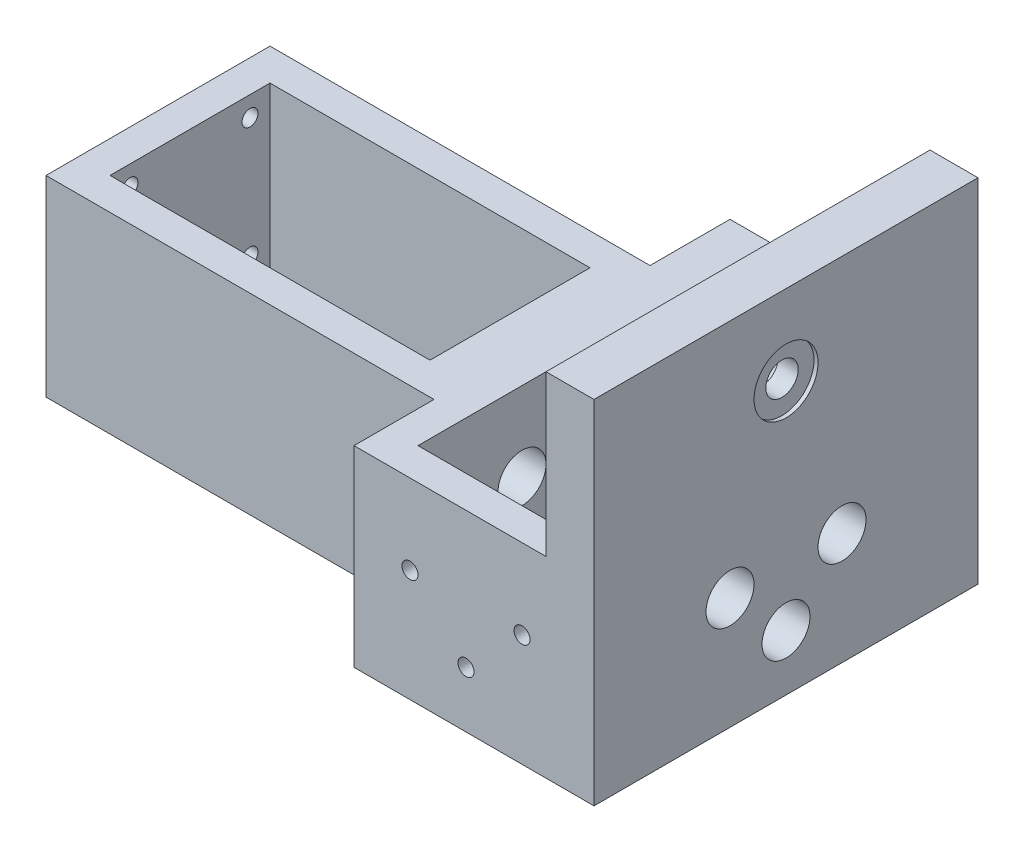
from build123d import *

# Parameters (mm, degrees)
BOSS_EXTRUDE1_DEPTH   = 5
SKETCH2_W             = 20
SKETCH2_H             = 40
SKETCH2_W_2           = 5
SKETCH2_H_2           = 20
BOSS_EXTRUDE2_DEPTH   = 20
SKETCH3_W             = 48.5
SKETCH3_H             = 25
BOSS_EXTRUDE3_DEPTH   = 4
SKETCH4_W             = 48.5
SKETCH4_H             = 25
BOSS_EXTRUDE4_DEPTH   = 4
SKETCH6_W             = 293.991294913
SKETCH6_H             = 166.612051016
CUT_EXTRUDE1_DEPTH    = 218
SKETCH7_W             = 4
SKETCH7_H             = 48
BOSS_EXTRUDE5_DEPTH   = 20
SKETCH8_W             = 48
SKETCH8_H             = 1
CUT_EXTRUDE2_DEPTH    = 87
SKETCH9_R             = 1
CUT_EXTRUDE3_DEPTH    = 10
SKETCH10_R            = 1
CUT_EXTRUDE4_DEPTH    = 60
SKETCH12_R            = 3
CUT_EXTRUDE5_DEPTH    = 29.5
SKETCH13_R            = 1
CUT_EXTRUDE6_DEPTH    = 29.5
SKETCH14_R            = 1
CUT_EXTRUDE7_DEPTH    = 29.5
SKETCH15_R            = 1.775
CUT_EXTRUDE8_DEPTH    = 29.5
SKETCH16_R            = 2.025
CUT_EXTRUDE9_DEPTH    = 29.5
SKETCH17_R            = 3.5
CUT_EXTRUDE10_DEPTH   = 3
SKETCH18_W            = 48
SKETCH18_H            = 44
SKETCH18_R            = 2.025
SKETCH18_R_2          = 3
BOSS_EXTRUDE6_DEPTH   = 2
CROQUIS2_R            = 4
CORTAR_EXTRUIR2_DEPTH = 0.5


with BuildPart() as part:
    # Sketch1 → Boss-Extrude1 (new body)
    with BuildSketch(Plane(origin=(0, 0, 0), x_dir=(1, 0, 0), z_dir=(0, 1, 0))):
        Polygon((-5, 20), (43.5, 20), (43.5, 35), (73.5, 35), (73.5, -15), (43.5, -15), (43.5, 0), (-5, 0), align=None)
    extrude(amount=BOSS_EXTRUDE1_DEPTH)

    # Sketch2 → Boss-Extrude2 (add)
    with BuildSketch(Plane(origin=(0, 5, 0), x_dir=(1, 0, 0), z_dir=(0, 1, 0))):
        Polygon((40, 20), (43.5, 20), (43.5, 35), (73.5, 35), (73.5, -15), (43.5, -15), (43.5, 0), (40, 0), align=None)
        with Locations((58.5, 10)):
            Rectangle(SKETCH2_W, SKETCH2_H, mode=Mode.SUBTRACT)
        with Locations((-2.5, 10)):
            Rectangle(SKETCH2_W_2, SKETCH2_H_2)
    extrude(amount=BOSS_EXTRUDE2_DEPTH)

    # Sketch3 → Boss-Extrude3 (add)
    with BuildSketch(Plane.XY):
        with Locations((19.25, 12.5)):
            Rectangle(SKETCH3_W, SKETCH3_H)
    extrude(amount=BOSS_EXTRUDE3_DEPTH)

    # Sketch4 → Boss-Extrude4 (add)
    with BuildSketch(Plane(origin=(0, 0, -20), x_dir=(-1, 0, 0), z_dir=(0, 0, -1))):
        with Locations((-19.25, 12.5)):
            Rectangle(SKETCH4_W, SKETCH4_H)
    extrude(amount=BOSS_EXTRUDE4_DEPTH)

    # Sketch6 → Cut-Extrude1 (cut)
    with BuildSketch(Plane.XZ):
        with Locations((19.737100805, -5.654680936)):
            Rectangle(SKETCH6_W, SKETCH6_H)
        Polygon((72.5, -34), (72.5, 14), (44.5, 14), (44.5, 4), (43.5, 4), (42.175115589, 8.832020086), (-3.564522491, 8.832020086), (-4, 4), (-4, -32.651206012), (43.5, -34), align=None, mode=Mode.SUBTRACT)
    extrude(amount=-CUT_EXTRUDE1_DEPTH, mode=Mode.SUBTRACT)

    # Sketch7 → Boss-Extrude5 (add)
    with BuildSketch(Plane(origin=(0, 25, 0), x_dir=(1, 0, 0), z_dir=(0, 1, 0))):
        with Locations((70.5, 10)):
            Rectangle(SKETCH7_W, SKETCH7_H)
    extrude(amount=BOSS_EXTRUDE5_DEPTH)

    # Sketch8 → Cut-Extrude2 (cut)
    with BuildSketch(Plane.ZY.offset(4)):
        with Locations((-10, 0.5)):
            Rectangle(SKETCH8_W, SKETCH8_H)
    extrude(amount=-CUT_EXTRUDE2_DEPTH, mode=Mode.SUBTRACT)

    # Sketch9 → Cut-Extrude3 (cut)
    with BuildSketch(Plane.ZY.offset(4)):
        with Locations((-2.5, 22.5)):
            Circle(SKETCH9_R)
        with Locations((-17.5, 22.5)):
            Circle(SKETCH9_R)
        with Locations((-17.5, 7.5)):
            Circle(SKETCH9_R)
        with Locations((-2.5, 7.5)):
            Circle(SKETCH9_R)
    extrude(amount=-CUT_EXTRUDE3_DEPTH, mode=Mode.SUBTRACT)

    # Sketch10 → Cut-Extrude4 (cut)
    with BuildSketch(Plane.ZY.offset(-40)):
        with Locations((-3, 15)):
            Circle(SKETCH10_R)
        with Locations((-10, 8)):
            Circle(SKETCH10_R)
        with Locations((-17, 15)):
            Circle(SKETCH10_R)
    extrude(amount=-CUT_EXTRUDE4_DEPTH, mode=Mode.SUBTRACT)

    # Sketch12 → Cut-Extrude5 (cut)
    with BuildSketch(Plane(origin=(72.5, 0, 0), x_dir=(0, 0, -1), z_dir=(1, 0, 0))):
        with Locations((17, 15)):
            Circle(SKETCH12_R)
        with Locations((10, 8)):
            Circle(SKETCH12_R)
        with Locations((3, 15)):
            Circle(SKETCH12_R)
    extrude(amount=-CUT_EXTRUDE5_DEPTH, mode=Mode.SUBTRACT)

    # Sketch13 → Cut-Extrude6 (cut)
    with BuildSketch(Plane.XY.offset(14)):
        with Locations((58.5, 8)):
            Circle(SKETCH13_R)
        with Locations((51.5, 15)):
            Circle(SKETCH13_R)
        with Locations((65.5, 15)):
            Circle(SKETCH13_R)
    extrude(amount=-CUT_EXTRUDE6_DEPTH, mode=Mode.SUBTRACT)

    # Sketch14 → Cut-Extrude7 (cut)
    with BuildSketch(Plane.XY.offset(-30)):
        with Locations((66, 22.5)):
            Circle(SKETCH14_R)
        with Locations((66, 7.5)):
            Circle(SKETCH14_R)
        with Locations((51, 7.5)):
            Circle(SKETCH14_R)
        with Locations((51, 22.5)):
            Circle(SKETCH14_R)
    extrude(amount=-CUT_EXTRUDE7_DEPTH, mode=Mode.SUBTRACT)

    # Sketch15 → Cut-Extrude8 (cut)
    with BuildSketch(Plane(origin=(72.5, 0, 0), x_dir=(0, 0, -1), z_dir=(1, 0, 0))):
        with Locations((10, 35)):
            Circle(SKETCH15_R)
    extrude(amount=-CUT_EXTRUDE8_DEPTH, mode=Mode.SUBTRACT)

    # Sketch16 → Cut-Extrude9 (cut)
    with BuildSketch(Plane.ZY.offset(-68.5)):
        with Locations((-10, 35)):
            Circle(SKETCH16_R)
    extrude(amount=-CUT_EXTRUDE9_DEPTH, mode=Mode.SUBTRACT)

    # Sketch17 → Cut-Extrude10 (cut)
    with BuildSketch(Plane.ZY.offset(-68.5)):
        with Locations((-10, 35)):
            Circle(SKETCH17_R)
    extrude(amount=-CUT_EXTRUDE10_DEPTH, mode=Mode.SUBTRACT)

    # Sketch18 → Boss-Extrude6 (add)
    with BuildSketch(Plane(origin=(72.5, 0, 0), x_dir=(0, 0, -1), z_dir=(1, 0, 0))):
        with Locations((10, 23)):
            Rectangle(SKETCH18_W, SKETCH18_H)
        with Locations((10, 35)):
            Circle(SKETCH18_R, mode=Mode.SUBTRACT)
        with Locations((17, 15)):
            Circle(SKETCH18_R_2, mode=Mode.SUBTRACT)
        with Locations((10, 8)):
            Circle(SKETCH18_R_2, mode=Mode.SUBTRACT)
        with Locations((3, 15)):
            Circle(SKETCH18_R_2, mode=Mode.SUBTRACT)
    extrude(amount=BOSS_EXTRUDE6_DEPTH)

    # Croquis2 → Cortar-Extruir2 (cut)
    with BuildSketch(Plane(origin=(74.5, 0, 0), x_dir=(0, 0, -1), z_dir=(1, 0, 0))):
        with Locations((10, 35)):
            Circle(CROQUIS2_R)
    extrude(amount=-CORTAR_EXTRUIR2_DEPTH, mode=Mode.SUBTRACT)


solid = part.part
